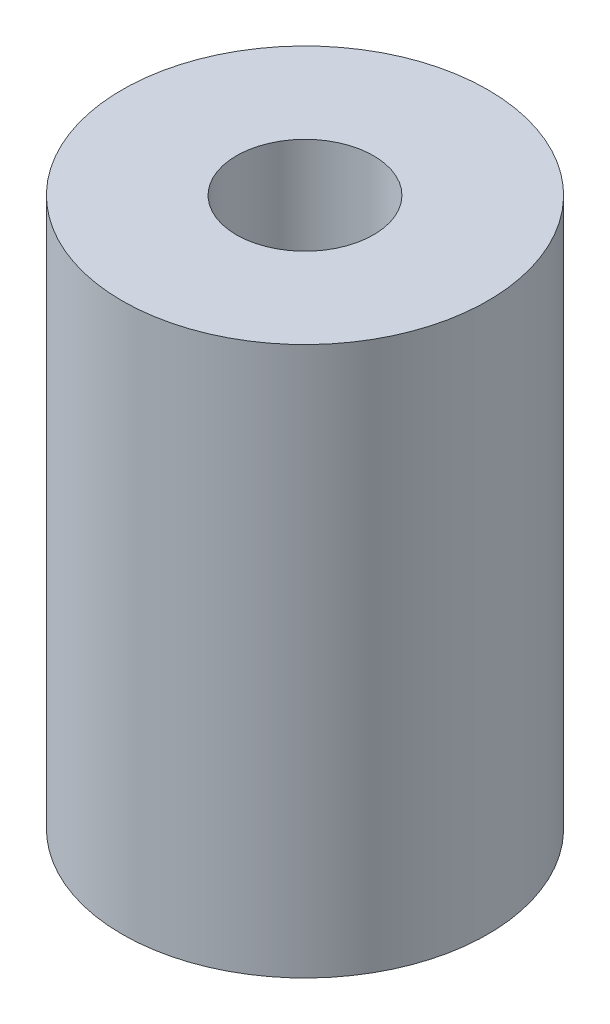
from build123d import *

# Parameters (mm, degrees)
ESQUISSE1_R        = 4
ESQUISSE1_R_2      = 1.5
BOSS_EXTRU_1_DEPTH = 12


with BuildPart() as part:
    # Esquisse1 → Boss.-Extru.1 (new body)
    with BuildSketch(Plane(origin=(0, 0, 0), x_dir=(1, 0, 0), z_dir=(0, 1, 0))):
        Circle(ESQUISSE1_R)
        Circle(ESQUISSE1_R_2, mode=Mode.SUBTRACT)
    extrude(amount=BOSS_EXTRU_1_DEPTH)


solid = part.part
